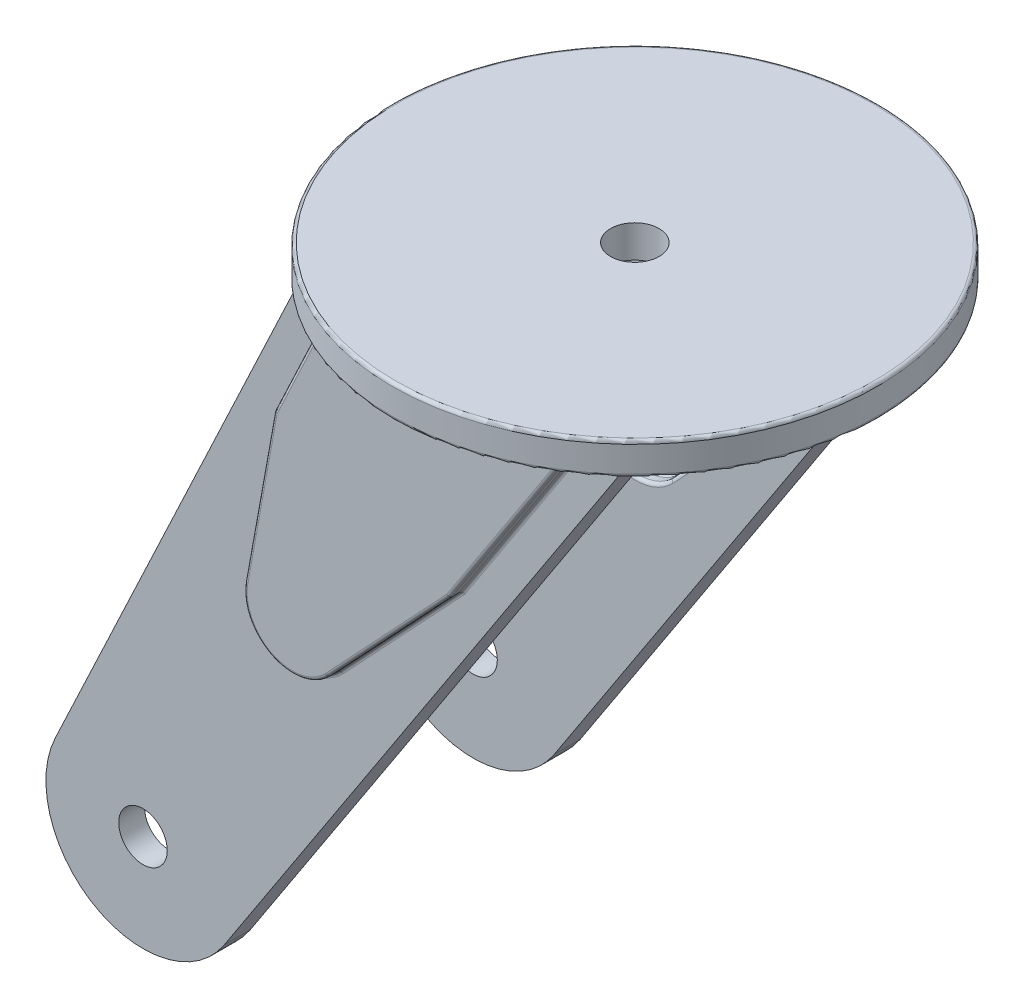
from build123d import *

# Parameters (mm, degrees)
SKETCH1_R            = 75
BOSS_EXTRUDE1_DEPTH  = 10
FILLET1_R            = 1
SKETCH2_R            = 7.5
BOSS_EXTRUDE2_DEPTH  = 8
BOSS_EXTRUDE3_DEPTH  = 4
FILLET2_R            = 1
CUT_EXTRUDE1_DEPTH   = 4
FILLET3_R            = 1
FILLET2_OF_MIRROR1_R = 1
FILLET3_OF_MIRROR1_R = 1
SKETCH5_R            = 7.5
CUT_EXTRUDE2_DEPTH   = 211
SCALE1_SCALE         = 0.18
SCALE2_SCALE         = 1.04


with BuildPart() as part:
    # Sketch1 → Boss-Extrude1 (new body)
    with BuildSketch(Plane(origin=(0, 0, 0), x_dir=(1, 0, 0), z_dir=(0, 1, 0))):
        Circle(SKETCH1_R)
    extrude(amount=BOSS_EXTRUDE1_DEPTH)

    # Fillet1
    fillet1_edges = [part.edges().sort_by_distance(p)[0] for p in [
        (-75, 0, 0),
        (-75, 10, 0),
    ]]
    fillet(fillet1_edges, radius=FILLET1_R)

    # Sketch2 → Boss-Extrude2 (add)
    with BuildSketch(Plane.XY.offset(47)):
        with BuildLine():
            Line((0, 0), (50, 0))
            Line((50, 0), (-71.891069435, -186.417722312))
            ThreePointArc((-71.891069435, -186.417722312), (-111.641881564, -196.184256802), (-124.134191379, -157.204076501))
            Line((-124.134191379, -157.204076501), (-50, 0))
            Line((-50, 0), (0, 0))
        make_face()
        with Locations((-97, -170)):
            Circle(SKETCH2_R, mode=Mode.SUBTRACT)
    boss_extrude2 = extrude(amount=BOSS_EXTRUDE2_DEPTH)

    # Sketch3 → Boss-Extrude3 (add)
    with BuildSketch(Plane.XY.offset(55)):
        with BuildLine():
            Line((37.5, 0), (1.66231791, -54.809422045))
            Line((1.66231791, -54.809422045), (-35.87268475, -94.809422045))
            ThreePointArc((-35.87268475, -94.809422045), (-53.553867963, -97.944214465), (-61.57168818, -81.876678179))
            Line((-61.57168818, -81.876678179), (-52.532382195, -31.876678179))
            Line((-52.532382195, -31.876678179), (-37.5, 0))
            Line((-37.5, 0), (37.5, 0))
        make_face()
    boss_extrude3 = extrude(amount=BOSS_EXTRUDE3_DEPTH)

    # Fillet2
    fillet2_edges = [part.edges().sort_by_distance(p)[0] for p in [
        (-45.016191098, -15.938339089, 55),
        (-57.052035188, -56.876678179, 55),
        (-53.553867963, -97.944214465, 55),
        (-17.10518342, -74.809422045, 55),
        (19.581158955, -27.404711022, 55),
        (-45.016191098, -15.938339089, 59),
        (-57.052035188, -56.876678179, 59),
        (-53.553867963, -97.944214465, 59),
        (-17.10518342, -74.809422045, 59),
        (19.581158955, -27.404711022, 59),
    ]]
    fillet(fillet2_edges, radius=FILLET2_R)

    # Sketch4 → Cut-Extrude1 (cut)
    with BuildSketch(Plane(origin=(0, 0, 47), x_dir=(-1, 0, 0), z_dir=(0, 0, -1))):
        with BuildLine():
            Line((37.5, 0), (52.532382195, -31.876678179))
            Line((52.532382195, -31.876678179), (61.57168818, -81.876678179))
            ThreePointArc((61.57168818, -81.876678179), (53.553867963, -97.944214465), (35.87268475, -94.809422045))
            Line((35.87268475, -94.809422045), (-1.66231791, -54.809422045))
            Line((-1.66231791, -54.809422045), (-37.5, 0))
            Line((-37.5, 0), (37.5, 0))
        make_face()
    cut_extrude1 = extrude(amount=-CUT_EXTRUDE1_DEPTH, mode=Mode.SUBTRACT)

    # Fillet3
    fillet3_edges = [part.edges().sort_by_distance(p)[0] for p in [
        (-45.016191098, -15.938339089, 51),
        (-57.052035188, -56.876678179, 51),
        (-53.553867963, -97.944214465, 51),
        (-17.10518342, -74.809422045, 51),
        (19.581158955, -27.404711022, 51),
        (19.581158955, -27.404711022, 47),
        (-17.10518342, -74.809422045, 47),
        (-53.553867963, -97.944214465, 47),
        (-57.052035188, -56.876678179, 47),
        (-45.016191098, -15.938339089, 47),
    ]]
    fillet(fillet3_edges, radius=FILLET3_R)

    # Mirror1: Boss-Extrude2, Boss-Extrude3, Cut-Extrude1 across plane
    add(boss_extrude2.mirror(Plane.XY))
    add(boss_extrude3.mirror(Plane.XY))
    add(cut_extrude1.mirror(Plane.XY), mode=Mode.SUBTRACT)

    # Fillet2 of Mirror1
    fillet2_of_mirror1_edges = [part.edges().sort_by_distance(p)[0] for p in [
        (-45.016191098, -15.938339089, -55),
        (-57.052035188, -56.876678179, -55),
        (-53.553867963, -97.944214465, -55),
        (-17.10518342, -74.809422045, -55),
        (19.581158955, -27.404711022, -55),
        (-45.016191098, -15.938339089, -59),
        (-57.052035188, -56.876678179, -59),
        (-53.553867963, -97.944214465, -59),
        (-17.10518342, -74.809422045, -59),
        (19.581158955, -27.404711022, -59),
    ]]
    fillet(fillet2_of_mirror1_edges, radius=FILLET2_OF_MIRROR1_R)

    # Fillet3 of Mirror1
    fillet3_of_mirror1_edges = [part.edges().sort_by_distance(p)[0] for p in [
        (-45.016191098, -15.938339089, -51),
        (-57.052035188, -56.876678179, -51),
        (-53.553867963, -97.944214465, -51),
        (-17.10518342, -74.809422045, -51),
        (19.581158955, -27.404711022, -51),
        (19.581158955, -27.404711022, -47),
        (-17.10518342, -74.809422045, -47),
        (-53.553867963, -97.944214465, -47),
        (-57.052035188, -56.876678179, -47),
        (-45.016191098, -15.938339089, -47),
    ]]
    fillet(fillet3_of_mirror1_edges, radius=FILLET3_OF_MIRROR1_R)

    # Sketch5 → Cut-Extrude2 (cut, through all)
    with BuildSketch(Plane(origin=(0, 10, 0), x_dir=(1, 0, 0), z_dir=(0, 1, 0))):
        Circle(SKETCH5_R)
    extrude(amount=-CUT_EXTRUDE2_DEPTH, mode=Mode.SUBTRACT)


with BuildPart() as part_1:
    # Scale1: scaled about (-28.841242381, -49.867797095, 0)
    add(part.part.scale(SCALE1_SCALE).moved(Location((-23.649818752, -40.891593618, 0))))


with BuildPart() as part_2:
    # Scale2: scaled about (-28.841242381, -49.867797095, 0)
    add(part_1.part.scale(SCALE2_SCALE).moved(Location((1.153649695, 1.994711884, 0))))


solid = part_2.part
